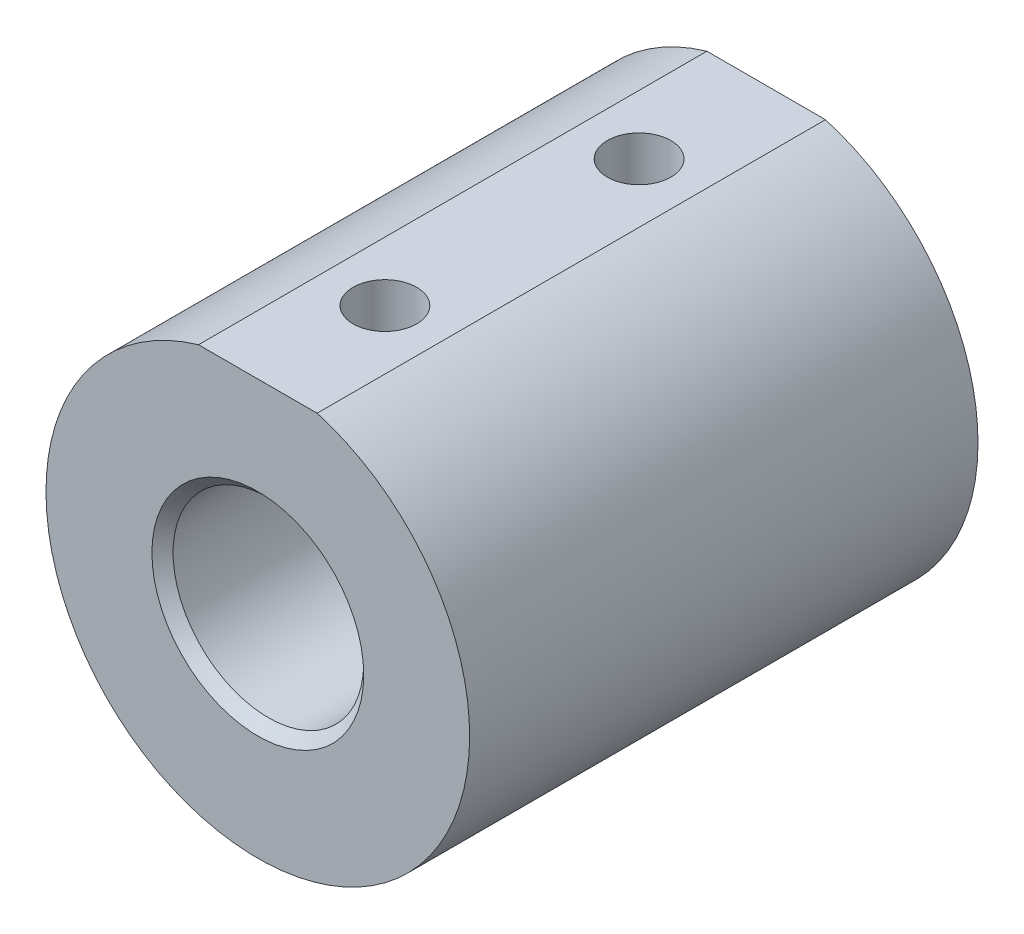
from build123d import *

# Parameters (mm, degrees)
SKETCH1_R           = 14.2875
BOSS_EXTRUDE1_DEPTH = 76.2
CUT_EXTRUDE1_REACH  = 64.23
SKETCH2_R           = 4.7625
CHAMFER1_SIZE       = 1.5875


with BuildPart() as part:
    # Sketch1 → Boss-Extrude1 (new body)
    with BuildSketch(Plane.XY):
        with BuildLine():
            Line((8.89, 30.48), (-8.89, 30.48))
            ThreePointArc((-8.89, 30.48), (-19.05, -25.4), (31.75, 0))
            ThreePointArc((31.75, 0), (25.4, 19.05), (8.89, 30.48))
        make_face()
        Circle(SKETCH1_R, mode=Mode.SUBTRACT)
    extrude(amount=BOSS_EXTRUDE1_DEPTH)

    # Sketch2 → Cut-Extrude1 (cut, up to next)
    with BuildSketch(Plane(origin=(0, 30.48, 0), x_dir=(1, 0, 0), z_dir=(0, 1, 0)), mode=Mode.PRIVATE) as cut_extrude1_sk1:
        with Locations((0, -57.15)):
            Circle(SKETCH2_R)
    cut_extrude1_tool1 = extrude(cut_extrude1_sk1.sketch, amount=-CUT_EXTRUDE1_REACH, mode=Mode.PRIVATE) & part.part
    add(cut_extrude1_tool1.solids().sort_by_distance((0, 30.48, 57.15))[0], mode=Mode.SUBTRACT)
    # Sketch2 → Cut-Extrude1 (cut, up to next)
    with BuildSketch(Plane(origin=(0, 30.48, 0), x_dir=(1, 0, 0), z_dir=(0, 1, 0)), mode=Mode.PRIVATE) as cut_extrude1_sk2:
        with Locations((0, -19.05)):
            Circle(SKETCH2_R)
    cut_extrude1_tool2 = extrude(cut_extrude1_sk2.sketch, amount=-CUT_EXTRUDE1_REACH, mode=Mode.PRIVATE) & part.part
    add(cut_extrude1_tool2.solids().sort_by_distance((0, 30.48, 19.05))[0], mode=Mode.SUBTRACT)

    # Chamfer1
    chamfer1_edges = [part.edges().sort_by_distance(p)[0] for p in [
        (-14.2875, 0, 0),
        (-14.2875, 0, 76.2),
    ]]
    chamfer(chamfer1_edges, length=CHAMFER1_SIZE)


solid = part.part
